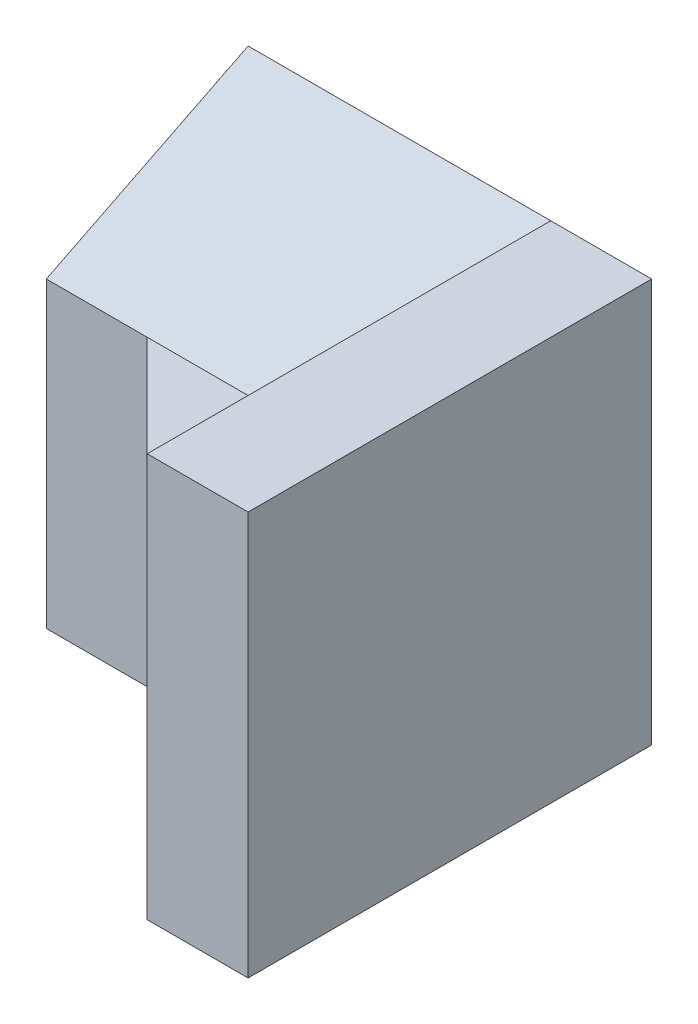
from build123d import *

# Parameters (mm, degrees)
BOSS_EXTRUDE1_DEPTH = 3
SKETCH2_W           = 4
SKETCH2_H           = 4
BOSS_EXTRUDE2_DEPTH = 1
SKETCH3_W           = 2
SKETCH3_H           = 1.741265719
BOSS_EXTRUDE3_DEPTH = 2
CUT_EXTRUDE1_DEPTH  = 2


with BuildPart() as part:
    # Sketch1 → Boss-Extrude1 (new body)
    with BuildSketch(Plane(origin=(0, 0, 0), x_dir=(0, 0, -1), z_dir=(1, 0, 0))):
        Polygon((0, 0), (2, 0), (2, 4), (0, 3), align=None)
    extrude(amount=BOSS_EXTRUDE1_DEPTH)

    # Sketch2 → Boss-Extrude2 (add)
    with BuildSketch(Plane(origin=(3, 0, 0), x_dir=(0, 0, -1), z_dir=(1, 0, 0))):
        with Locations((0, 2)):
            Rectangle(SKETCH2_W, SKETCH2_H)
    extrude(amount=BOSS_EXTRUDE2_DEPTH)

    # Sketch3 → Boss-Extrude3 (add)
    with BuildSketch(Plane.ZY.offset(-3)):
        with Locations((1, 2.129367141)):
            Rectangle(SKETCH3_W, SKETCH3_H)
    extrude(amount=BOSS_EXTRUDE3_DEPTH)

    # Sketch4 → Cut-Extrude1 (cut)
    with BuildSketch(Plane(origin=(0, 3, 0), x_dir=(1, 0, 0), z_dir=(0, 1, 0))):
        Polygon((1, 0), (3, -2), (1, -2), align=None)
    extrude(amount=-CUT_EXTRUDE1_DEPTH, mode=Mode.SUBTRACT)


solid = part.part
